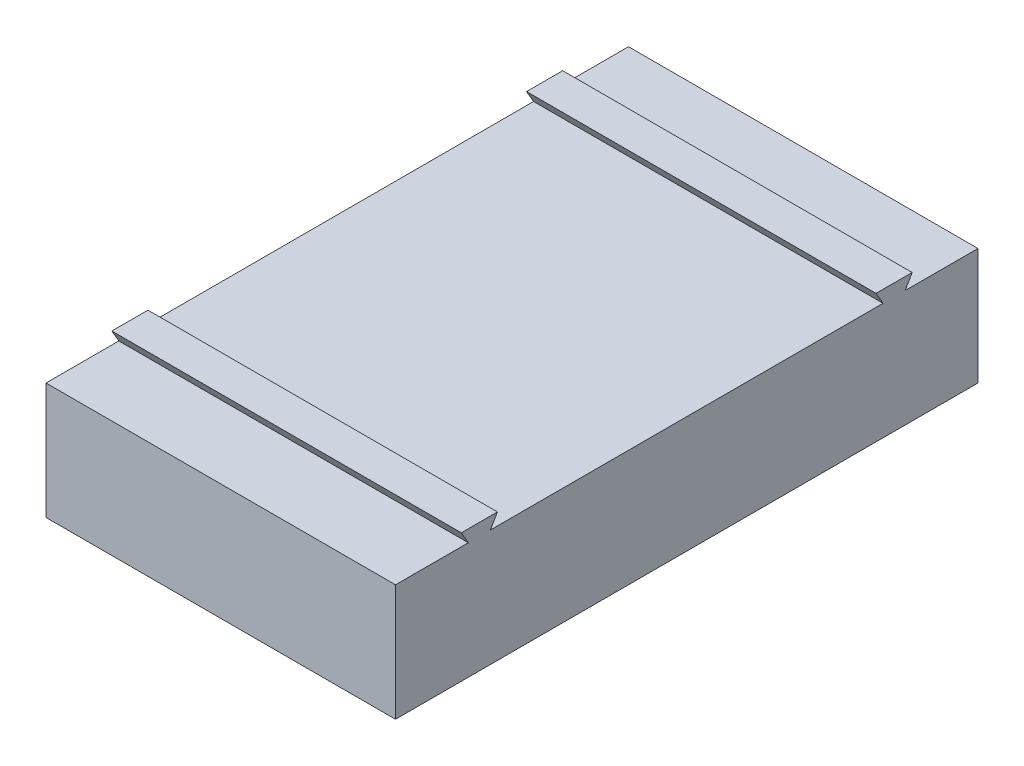
from build123d import *

# Parameters (mm, degrees)
SKETCH1_W           = 120
SKETCH1_H           = 200
BOSS_EXTRUDE1_DEPTH = 40
BOSS_EXTRUDE2_DEPTH = 120
CUT_EXTRUDE2_DEPTH  = 1


with BuildPart() as part:
    # Sketch1 → Boss-Extrude1 (new body)
    with BuildSketch(Plane(origin=(0, 0, 0), x_dir=(1, 0, 0), z_dir=(0, 1, 0))):
        Rectangle(SKETCH1_W, SKETCH1_H)
    extrude(amount=BOSS_EXTRUDE1_DEPTH)

    # Sketch2 → Boss-Extrude2 (add)
    with BuildSketch(Plane(origin=(60, 0, 0), x_dir=(0, 0, -1), z_dir=(1, 0, 0))):
        Polygon((67.4, 40), (64.99822288, 44.16), (77.40177712, 44.16), (75, 40), align=None)
        Polygon((-75, 40), (-77.40177712, 44.16), (-64.99822288, 44.16), (-67.4, 40), align=None)
    extrude(amount=-BOSS_EXTRUDE2_DEPTH)

    # Sketch5 → Cut-Extrude2 (cut)
    with BuildSketch(Plane.XZ):
        Polygon((-10.888743303, -30.135074667), (-10.888743303, 13.324383252), (-25.483702069, 13.324383252), (0, 40.546241509), (25.483702069, 13.324383252), (10.888743303, 13.324383252), (10.888743303, -30.135074667), align=None)
    extrude(amount=-CUT_EXTRUDE2_DEPTH, mode=Mode.SUBTRACT)


solid = part.part
